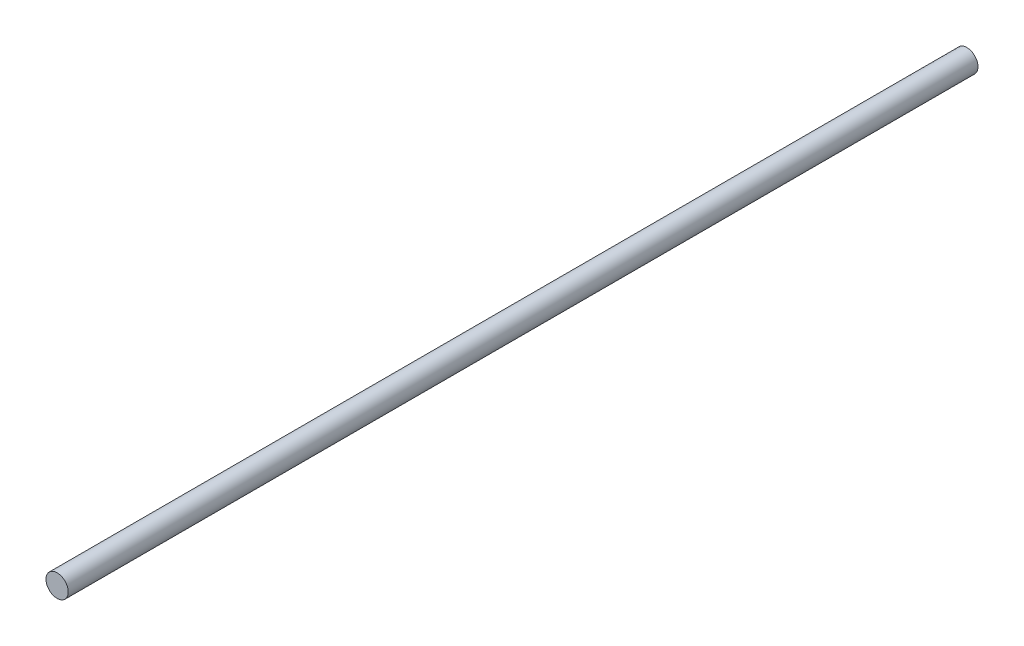
from build123d import *

# Parameters (mm, degrees)
SKETCH1_R           = 4
BOSS_EXTRUDE1_DEPTH = 163.5


with BuildPart() as part:
    # Sketch1 → Boss-Extrude1 (new body, symmetric)
    with BuildSketch(Plane.XY):
        Circle(SKETCH1_R)
    extrude(amount=BOSS_EXTRUDE1_DEPTH, both=True)


solid = part.part
